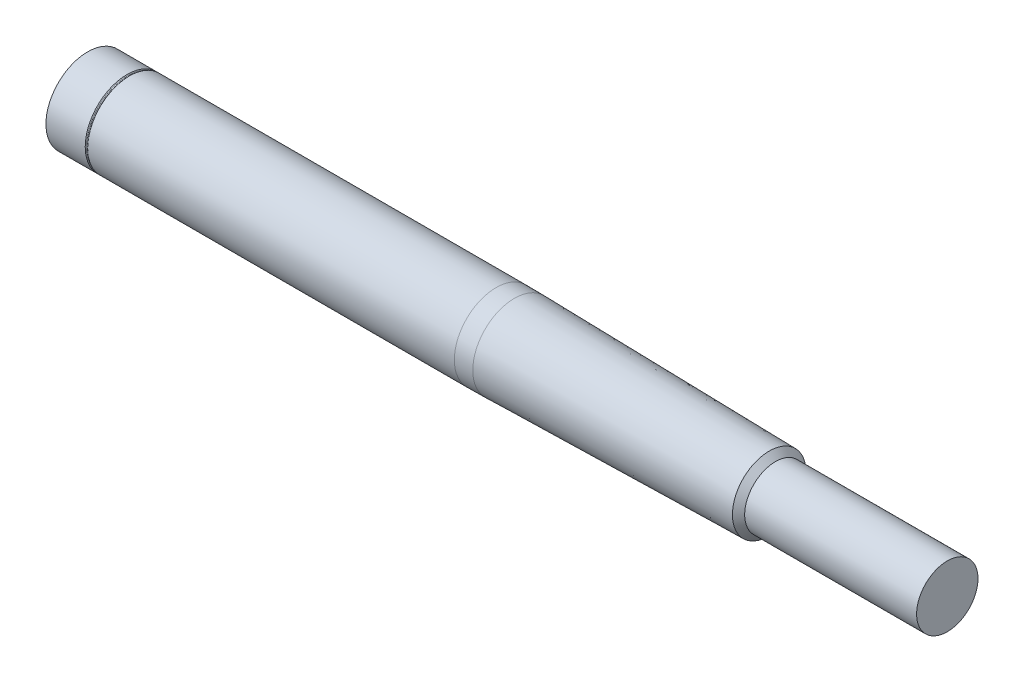
from build123d import *


with BuildPart() as part:
    # Skizze3 → Rotation1 (revolve)
    with BuildSketch(Plane(origin=(0, 0, 0), x_dir=(1, 0, 0), z_dir=(0, 1, 0))):
        with BuildLine():
            Line((175, 6.25), (140, 6.25))
            Line((140, 6.25), (138.75, 7.5))
            Line((138.75, 7.5), (86.859982279, 8.465395679))
            ThreePointArc((86.859982279, 8.465395679), (84.99991953, 8.491348733), (83.139695848, 8.5))
            Line((83.139695848, 8.5), (7.5, 8.5))
            Line((7.5, 8.5), (0, 8.5))
            Line((0, 8.5), (0, 0))
            Line((0, 0), (175, 0))
            Line((175, 0), (175, 6.25))
        make_face()
    revolve(axis=Axis((0, 0, 0), (-1, 0, 0)))

    # Skizze4 → Schnitt-Rotation1 (revolve, cut)
    with BuildSketch(Plane(origin=(0, 0, 0), x_dir=(1, 0, 0), z_dir=(0, 1, 0))):
        with BuildLine():
            Line((8, 8.5), (8.143933983, 8.356066017))
            ThreePointArc((8.143933983, 8.356066017), (8.25, 8.312132034), (8.356066017, 8.356066017))
            Line((8.356066017, 8.356066017), (8.5, 8.5))
            Line((8.5, 8.5), (8, 8.5))
        make_face()
    revolve(axis=Axis((0, 0, 0), (1, 0, 0)), mode=Mode.SUBTRACT)


solid = part.part
